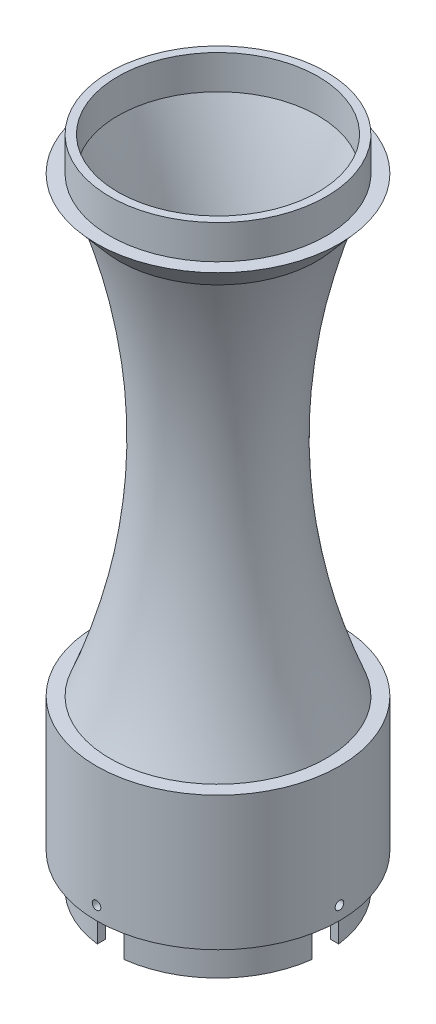
from build123d import *

# Parameters (mm, degrees)
CUT_EXTRUDE1_DEPTH = 22.7
SKETCH3_R          = 1.6
CUT_EXTRUDE2_DEPTH = 6
CIRPATTERN1_COUNT  = 4


with BuildPart() as part:
    # Sketch1 → Revolve1 (revolve)
    with BuildSketch(Plane.XY):
        with BuildLine():
            Line((0, 188.999977867), (0, 201.699977867))
            Line((0, 201.699977867), (-3, 201.699977867))
            Line((-3, 201.699977867), (-3, 188.999977867))
            Line((-3, 188.999977867), (-8, 188.999977867))
            Line((-8, 188.999977867), (0.570207018, 178.999977867))
            add(Edge.make_bspline(
                [(-3, 19.999977867), (17.518474446, 71.927932429), (18.708543453, 124.927932429), (0.570207018, 178.999977867)],
                knots=[0, 0, 0, 0, 0.942000122, 0.942000122, 0.942000122, 0.942000122], degree=3))
            Line((-3, 19.999977867), (-8, 19.999977867))
            Line((-8, 19.999977867), (-8, -30.000022133))
            Line((-8, -30.000022133), (-3, -30.000022133))
            Line((-3, -30.000022133), (-3, -42.700022133))
            Line((-3, -42.700022133), (0, -42.700022133))
            Line((0, -42.700022133), (0, -30.000022133))
            Line((0, -30.000022133), (0, 20.000038989))
            add(Edge.make_bspline(
                [(0, 20.000038989), (32.67273479, 102.687818928), (0, 188.999977867)],
                knots=[0, 0, 0, 1, 1, 1], degree=2))
        make_face()
    revolve(axis=Axis((37.402673701, -40.000005834, 0), (0, 1, 0)))

    # Sketch2 → Cut-Extrude1 (cut)
    with BuildSketch(Plane.XZ.offset(42.700022133)):
        with BuildLine():
            Line((25.405862227, 5), (-3, 5))
            Line((-3, 5), (-3, -5))
            Line((-3, -5), (25.405862227, -5))
            ThreePointArc((25.405862227, -5), (28.2123667, -9.190307001), (32.402673701, -11.996811474))
            Line((32.402673701, -11.996811474), (32.402673701, -40.402673701))
            Line((32.402673701, -40.402673701), (42.402673701, -40.402673701))
            Line((42.402673701, -40.402673701), (42.402673701, -11.996811474))
            ThreePointArc((42.402673701, -11.996811474), (46.592980702, -9.190307001), (49.399485175, -5))
            Line((49.399485175, -5), (77.805347402, -5))
            Line((77.805347402, -5), (77.805347402, 5))
            Line((77.805347402, 5), (49.399485175, 5))
            ThreePointArc((49.399485175, 5), (46.592980702, 9.190307001), (42.402673701, 11.996811474))
            Line((42.402673701, 11.996811474), (42.402673701, 40.402673701))
            Line((42.402673701, 40.402673701), (32.402673701, 40.402673701))
            Line((32.402673701, 40.402673701), (32.402673701, 11.996811474))
            ThreePointArc((32.402673701, 11.996811474), (28.2123667, 9.190307001), (25.405862227, 5))
        make_face()
    extrude(amount=-CUT_EXTRUDE1_DEPTH, mode=Mode.SUBTRACT)

    # Sketch3 → Cut-Extrude2 (cut, through all)
    with BuildSketch(Plane(origin=(-3, 0, 0), x_dir=(0, 0, -1), z_dir=(1, 0, 0))):
        with Locations((0, -25.000022133)):
            Circle(SKETCH3_R)
    cut_extrude2 = extrude(amount=-CUT_EXTRUDE2_DEPTH, mode=Mode.SUBTRACT)

    # CirPattern1: Cut-Extrude2 ×4 about axis
    cirpattern1_axis = Axis((37.402673701, 20.000038989, 0), (0, -1, 0))
    for i in range(1, CIRPATTERN1_COUNT):
        add(cut_extrude2.rotate(cirpattern1_axis, i * 360 / CIRPATTERN1_COUNT), mode=Mode.SUBTRACT)


solid = part.part
